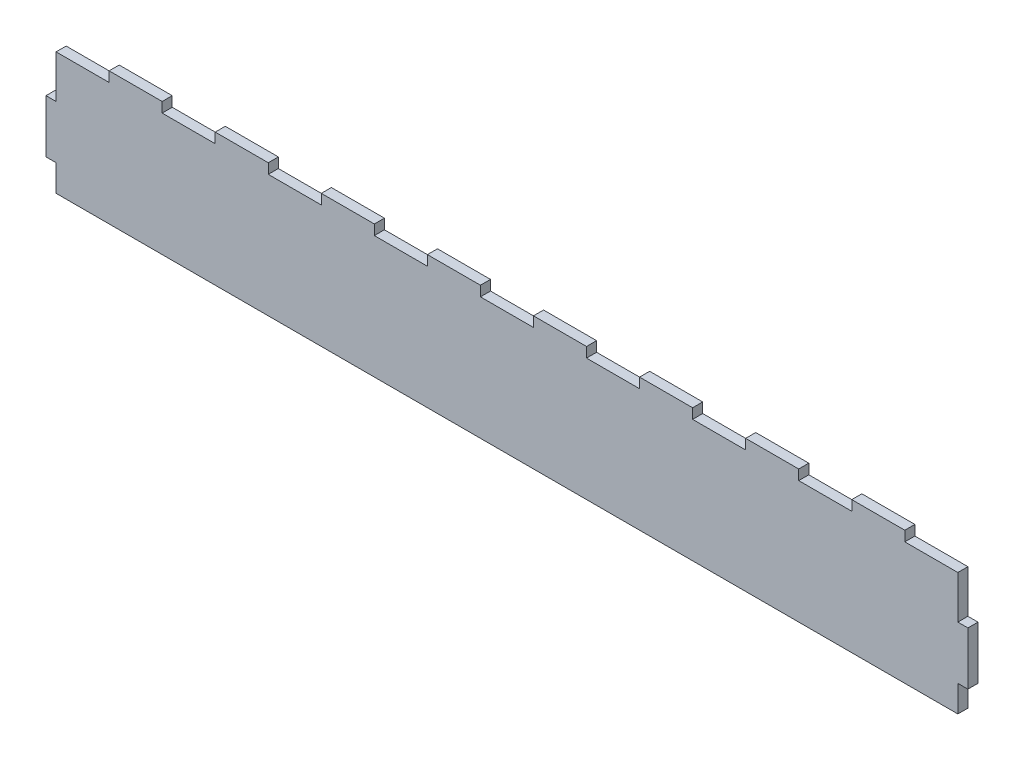
from build123d import *

# Parameters (mm, degrees)
BOSS_EXTRUDE1_DEPTH = 4.826


with BuildPart() as part:
    # Sketch1 → Boss-Extrude1 (new body)
    with BuildSketch(Plane.XY):
        Polygon((527.05, 12.7), (527.05, 0), (95.25, 0), (95.25, 12.7), (90.424, 12.7), (90.424, 38.1), (95.25, 38.1), (95.25, 58.674), (120.65, 58.674), (120.65, 63.5), (146.05, 63.5), (146.05, 58.674), (171.45, 58.674), (171.45, 63.5), (196.85, 63.5), (196.85, 58.674), (222.25, 58.674), (222.25, 63.5), (247.65, 63.5), (247.65, 58.674), (273.05, 58.674), (273.05, 63.5), (298.45, 63.5), (298.45, 58.674), (323.85, 58.674), (323.85, 63.5), (349.25, 63.5), (349.25, 58.674), (374.65, 58.674), (374.65, 63.5), (400.05, 63.5), (400.05, 58.674), (425.45, 58.674), (425.45, 63.5), (450.85, 63.5), (450.85, 58.674), (476.25, 58.674), (476.25, 63.5), (501.65, 63.5), (501.65, 58.674), (527.05, 58.674), (527.05, 38.1), (531.876, 38.1), (531.876, 12.7), align=None)
    extrude(amount=BOSS_EXTRUDE1_DEPTH)


solid = part.part
